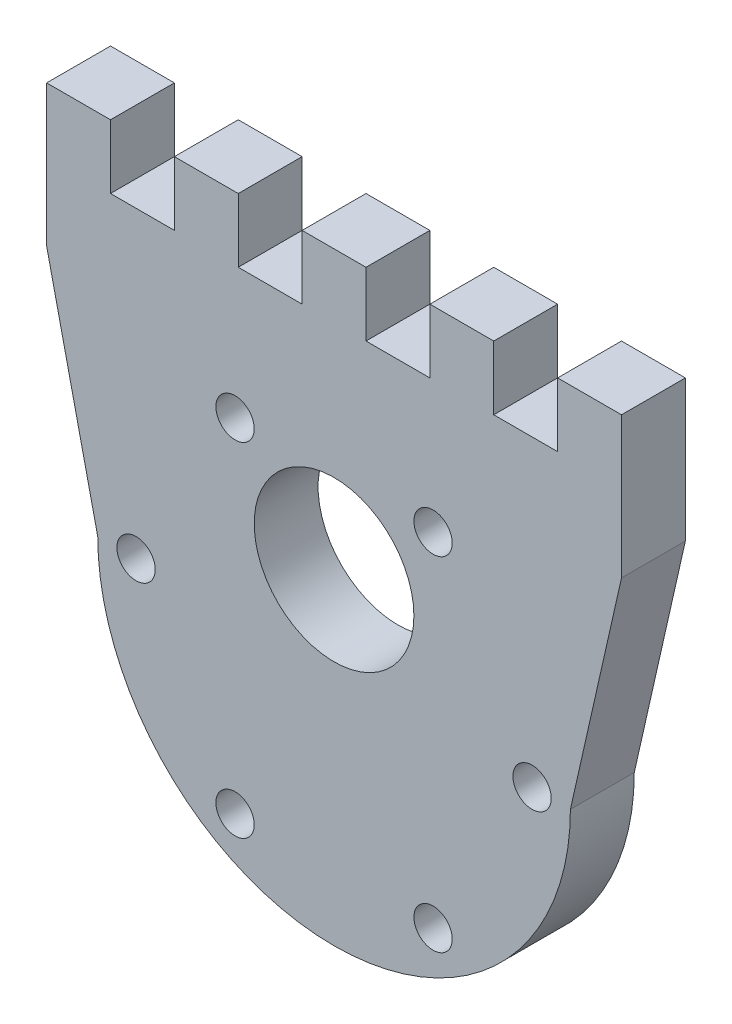
from build123d import *

# Parameters (mm, degrees)
BOSS_EXTRU_2_DEPTH           = 5
ESQUISSE2_R                  = 1.5
ENL_V_MAT_EXTRU_1_DEPTH      = 5
R_P_TITION_CIRCULAIRE1_COUNT = 6
ESQUISSE3_R                  = 6.25
ENL_V_MAT_EXTRU_2_DEPTH      = 5
ESQUISSE4_W                  = 5
ESQUISSE4_H                  = 5
ENL_V_MAT_EXTRU_3_DEPTH      = 10
R_P_TITION_LIN_AIRE1_COUNT   = 4
R_P_TITION_LIN_AIRE1_PITCH   = 10
ESQUISSE5_W                  = 11.156910716
ESQUISSE5_H                  = 32.673754016
ESQUISSE5_W_2                = 16.593305943
ENL_V_MAT_EXTRU_4_DEPTH      = 10


with BuildPart() as part:
    # Esquisse1 → Boss.-Extru.2 (new body)
    with BuildSketch(Plane.XY):
        with BuildLine():
            ThreePointArc((18.5, 0), (0, -18.5), (-18.5, 0))
            Line((-18.5, 0), (-25, 28.75))
            Line((-25, 28.75), (25, 28.75))
            Line((25, 28.75), (18.5, 0))
        make_face()
    extrude(amount=BOSS_EXTRU_2_DEPTH)

    # Esquisse2 → Enlèv. mat.-Extru.1 (cut)
    with BuildSketch(Plane.XY.offset(5)):
        with Locations((-7.75, -13.423393759)):
            Circle(ESQUISSE2_R)
    enl_v_mat_extru_1 = extrude(amount=-ENL_V_MAT_EXTRU_1_DEPTH, mode=Mode.SUBTRACT)

    # Répétition circulaire1: Enlèv. mat.-Extru.1 ×6 about axis
    r_p_tition_circulaire1_axis = Axis((0, 0, 0), (0, 0, 1))
    for i in range(1, R_P_TITION_CIRCULAIRE1_COUNT):
        add(enl_v_mat_extru_1.rotate(r_p_tition_circulaire1_axis, i * 360 / R_P_TITION_CIRCULAIRE1_COUNT), mode=Mode.SUBTRACT)

    # Esquisse3 → Enlèv. mat.-Extru.2 (cut)
    with BuildSketch(Plane.XY.offset(5)):
        with Locations((0, 7)):
            Circle(ESQUISSE3_R)
    extrude(amount=-ENL_V_MAT_EXTRU_2_DEPTH, mode=Mode.SUBTRACT)

    # Esquisse4 → Enlèv. mat.-Extru.3 (cut)
    with BuildSketch(Plane.XY.offset(5)):
        with Locations((-15, 26.25)):
            Rectangle(ESQUISSE4_W, ESQUISSE4_H)
    enl_v_mat_extru_3 = extrude(amount=-ENL_V_MAT_EXTRU_3_DEPTH, mode=Mode.SUBTRACT)

    # Répétition linéaire1: Enlèv. mat.-Extru.3 ×4
    with Locations(*[(i * R_P_TITION_LIN_AIRE1_PITCH, 0, 0) for i in range(1, R_P_TITION_LIN_AIRE1_COUNT)]):
        add(enl_v_mat_extru_3, mode=Mode.SUBTRACT)

    # Esquisse5 → Enlèv. mat.-Extru.4 (cut)
    with BuildSketch(Plane.XY.offset(5)):
        with Locations((28.078455358, 23.582495232)):
            Rectangle(ESQUISSE5_W, ESQUISSE5_H)
        with Locations((-30.796652972, 23.582495232)):
            Rectangle(ESQUISSE5_W_2, ESQUISSE5_H)
    extrude(amount=-ENL_V_MAT_EXTRU_4_DEPTH, mode=Mode.SUBTRACT)


solid = part.part
